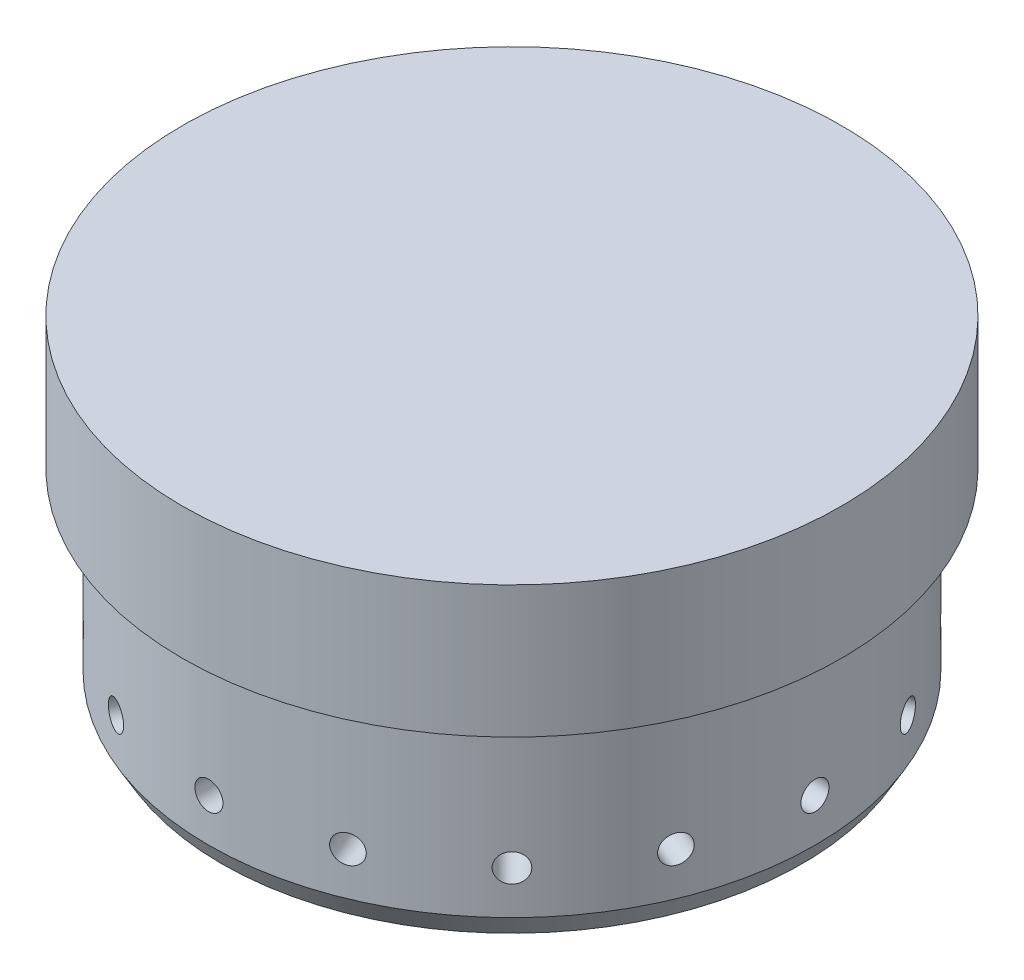
from build123d import *

# Parameters (mm, degrees)
TAP_PATTERN_COUNT = 16
CHAMFER1_SIZE     = 2.54
CHAMFER1_SIZE2    = 4.399409051


with BuildPart() as part:
    # Sketch1 → Revolve1 (revolve)
    with BuildSketch(Plane.XY):
        Polygon((0, 0), (-58.4454, 0), (-58.4454, 38.1), (-63.5, 38.1), (-63.5, 63.5), (0, 63.5), align=None)
    revolve(axis=Axis((0, 63.5, 0), (0, -1, 0)))

    # Sketch13 → 1/4-28 Tap (revolve, cut)
    with BuildSketch(Plane(origin=(0, 12.7, 58.4454), x_dir=(0, -1, 0), z_dir=(1, 0, 0))):
        Polygon((0, 0), (0, 20.675388061), (2.7051, 19.05), (2.7051, 0), align=None)
    f_1_4_28_tap = revolve(axis=Axis((0, 12.7, 64.7954), (0, 0, -1)), mode=Mode.SUBTRACT)

    # Tap Pattern: 1/4-28 Tap ×16 about axis
    tap_pattern_axis = Axis((0, 0, 0), (0, 1, 0))
    for i in range(1, TAP_PATTERN_COUNT):
        add(f_1_4_28_tap.rotate(tap_pattern_axis, i * 360 / TAP_PATTERN_COUNT), mode=Mode.SUBTRACT)

    # Chamfer1
    chamfer1_edges = [part.edges().sort_by_distance(p)[0] for p in [
        (58.4454, 0, 0),
    ]]
    chamfer1_side = [part.faces().sort_by_distance(p)[0] for p in [
        (0, 0, 0),
    ]]
    chamfer(chamfer1_edges, length=CHAMFER1_SIZE, length2=CHAMFER1_SIZE2, reference=chamfer1_side[0])


solid = part.part
